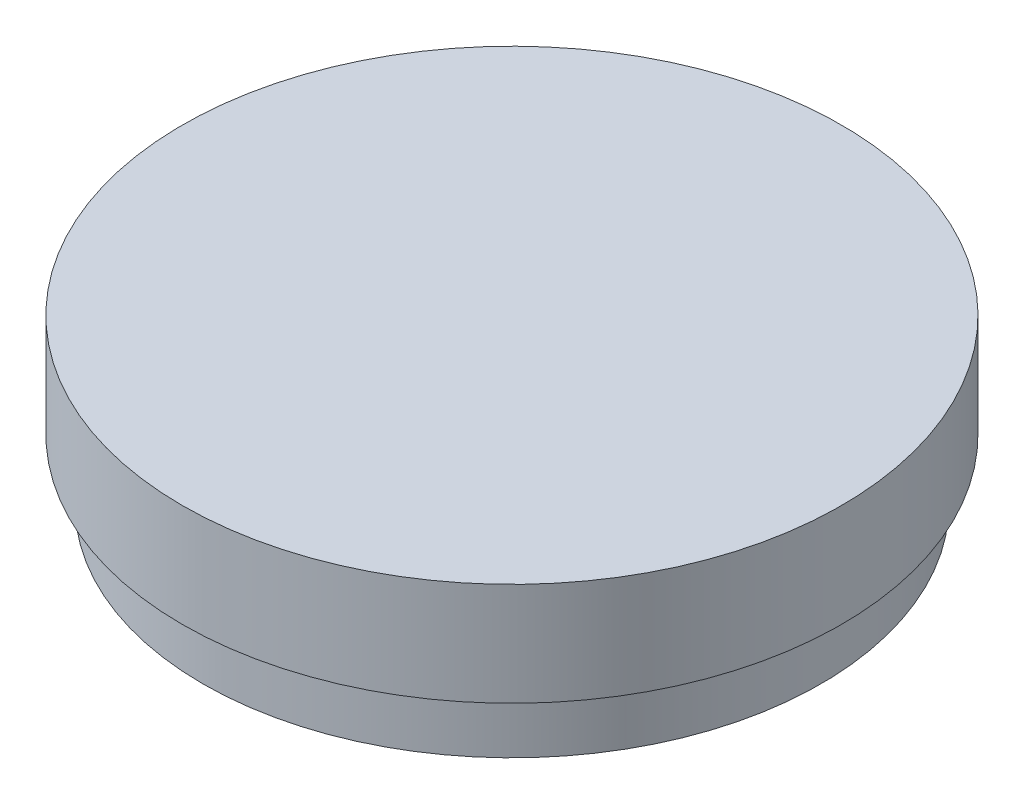
from build123d import *

# Parameters (mm, degrees)
SKETCH1_R           = 15
BOSS_EXTRUDE1_DEPTH = 3
SKETCH2_R           = 16
BOSS_EXTRUDE2_DEPTH = 5


with BuildPart() as part:
    # Sketch1 → Boss-Extrude1 (new body)
    with BuildSketch(Plane(origin=(0, 0, 0), x_dir=(1, 0, 0), z_dir=(0, 1, 0))):
        Circle(SKETCH1_R)
    extrude(amount=BOSS_EXTRUDE1_DEPTH)

    # Sketch2 → Boss-Extrude2 (add)
    with BuildSketch(Plane(origin=(0, 3, 0), x_dir=(1, 0, 0), z_dir=(0, 1, 0))):
        Circle(SKETCH2_R)
    extrude(amount=BOSS_EXTRUDE2_DEPTH)


solid = part.part
